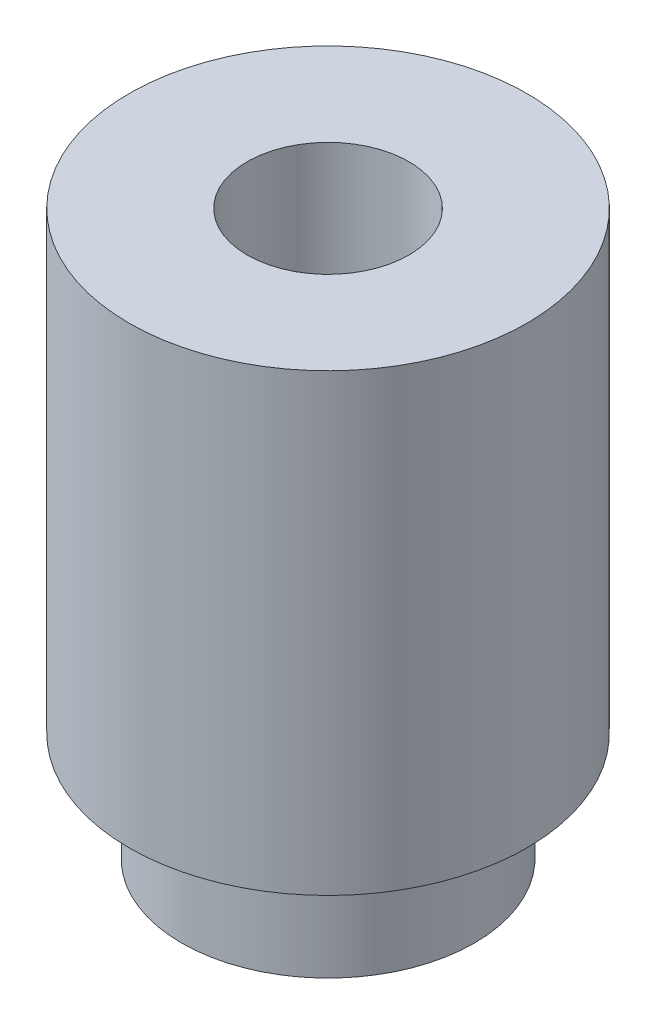
from build123d import *

# Parameters (mm, degrees)
SKETCH1_R             = 2.045
BOSS_EXTRUDE1_DEPTH   = 1.52
SKETCH2_R             = 2.78
BOSS_EXTRUDE2_DEPTH   = 6.35
F_4_40_TAPPED_HOLE1_D = 2.2606


with BuildPart() as part:
    # Sketch1 → Boss-Extrude1 (new body)
    with BuildSketch(Plane(origin=(0, 0, 0), x_dir=(1, 0, 0), z_dir=(0, 1, 0))):
        Circle(SKETCH1_R)
    extrude(amount=BOSS_EXTRUDE1_DEPTH)

    # Sketch2 → Boss-Extrude2 (add)
    with BuildSketch(Plane(origin=(0, 1.52, 0), x_dir=(1, 0, 0), z_dir=(0, 1, 0))):
        Circle(SKETCH2_R)
    extrude(amount=BOSS_EXTRUDE2_DEPTH)

    # #4-40 Tapped Hole1 (through all)
    with Locations(Plane(origin=(0, 7.87, 0), x_dir=(1, 0, 0), z_dir=(0, 1, 0))):
        with Locations((0, 0)):
            Hole(F_4_40_TAPPED_HOLE1_D / 2)


solid = part.part
